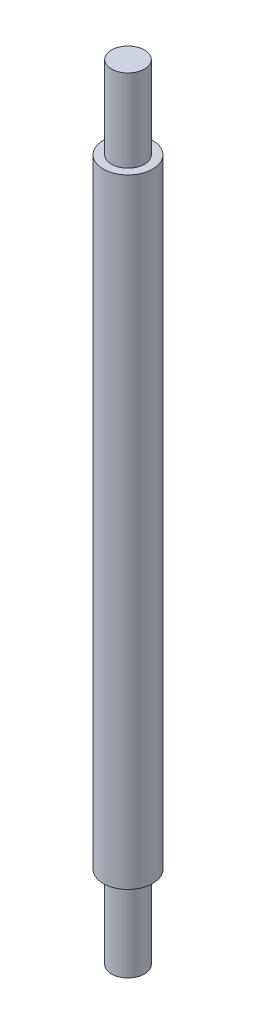
from build123d import *

# Parameters (mm, degrees)
SKETCH1_R           = 3
BOSS_EXTRUDE1_DEPTH = 75
SKETCH2_R           = 2
BOSS_EXTRUDE2_DEPTH = 10
SKETCH3_R           = 2
BOSS_EXTRUDE3_DEPTH = 10


with BuildPart() as part:
    # Sketch1 → Boss-Extrude1 (new body)
    with BuildSketch(Plane(origin=(0, 0, 0), x_dir=(1, 0, 0), z_dir=(0, 1, 0))):
        Circle(SKETCH1_R)
    extrude(amount=BOSS_EXTRUDE1_DEPTH)

    # Sketch2 → Boss-Extrude2 (add)
    with BuildSketch(Plane(origin=(0, 75, 0), x_dir=(1, 0, 0), z_dir=(0, 1, 0))):
        Circle(SKETCH2_R)
    extrude(amount=BOSS_EXTRUDE2_DEPTH)

    # Sketch3 → Boss-Extrude3 (add)
    with BuildSketch(Plane.XZ):
        Circle(SKETCH3_R)
    extrude(amount=BOSS_EXTRUDE3_DEPTH)


solid = part.part
